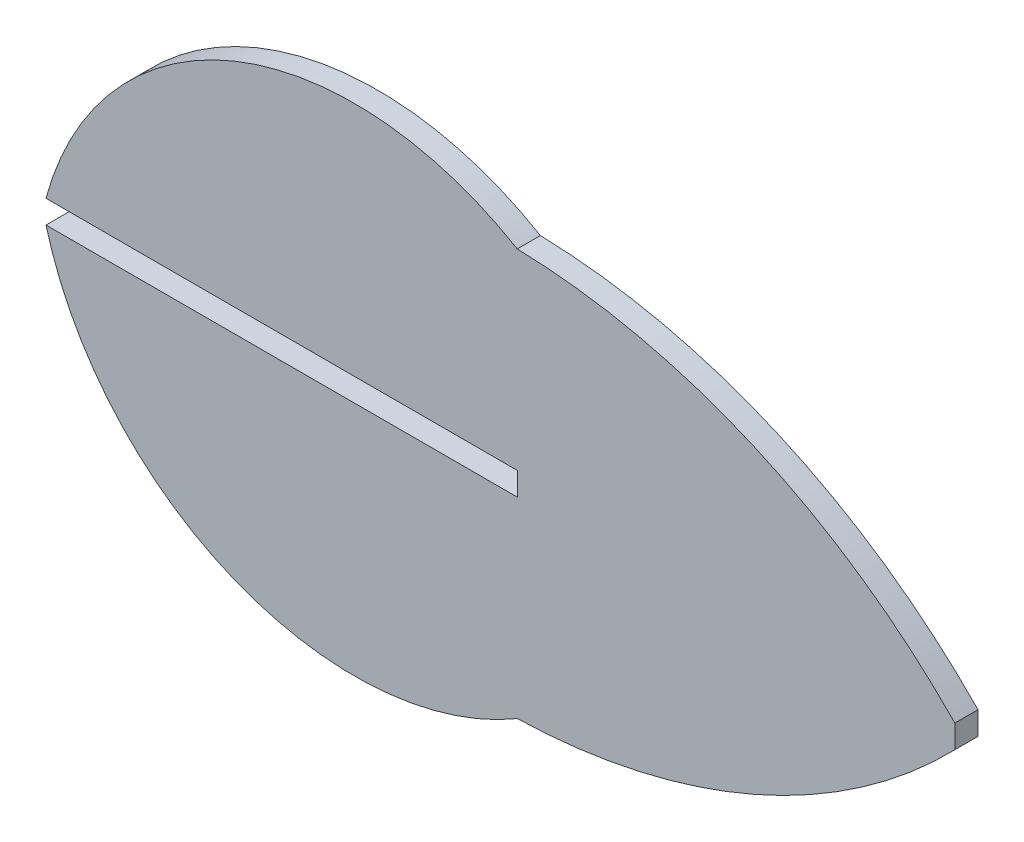
from build123d import *

# Parameters (mm, degrees)
BOSS_EXTRUDE1_DEPTH = 1.524


with BuildPart() as part:
    # Sketch1 → Boss-Extrude1 (new body)
    with BuildSketch(Plane.XY):
        with BuildLine():
            Line((82.44470135, -1.524), (82.44470135, 0))
            Line((82.44470135, 0), (51.403450054, 0))
            ThreePointArc((51.403450054, 0), (63.788927887, 14.019916875), (82.44470135, 12.634187153))
            ThreePointArc((82.44470135, 12.634187153), (98.093428139, 9.137765846), (111.269499156, 0))
            Line((111.269499156, 0), (111.269499156, -1.524))
            ThreePointArc((111.269499156, -1.524), (98.093428139, -10.661765846), (82.44470135, -14.158187153))
            ThreePointArc((82.44470135, -14.158187153), (63.788927887, -15.543916875), (51.403450054, -1.524))
            Line((51.403450054, -1.524), (82.44470135, -1.524))
        make_face()
    extrude(amount=BOSS_EXTRUDE1_DEPTH)


solid = part.part
